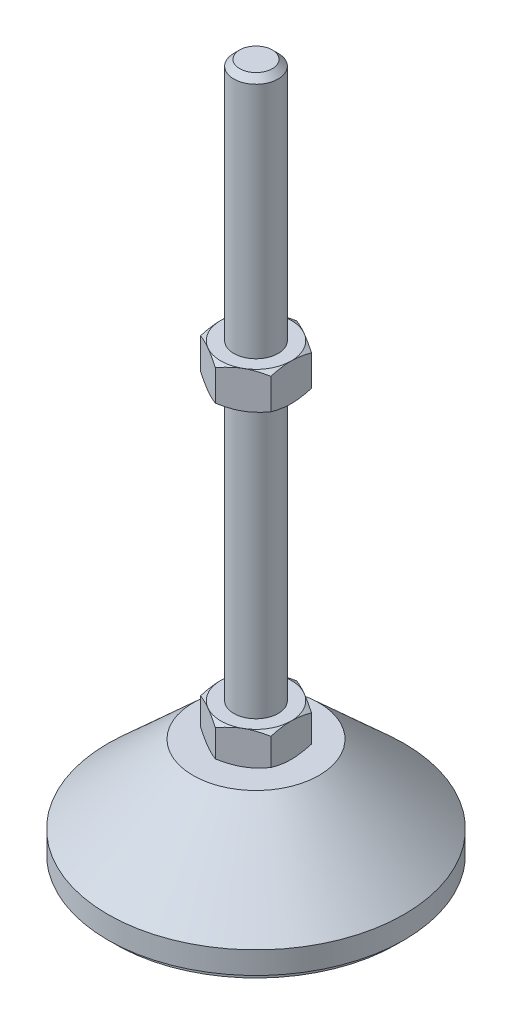
from build123d import *

# Parameters (mm, degrees)
EXTRUDE_1_DEPTH = 9
EXTRUDE_2_DEPTH = 10


with BuildPart() as part:
    # Эскиз1 → Повернуть1 (revolve)
    with BuildSketch(Plane.XY, mode=Mode.PRIVATE) as revolve_1_sk:
        Polygon((0, 0), (-38, 0), (-38, 2), (-40, 2), (-40, 8), (-17, 29), (-6, 29), (-6, 38), (-6, 186.4), (-4.4, 188), (0, 188), align=None)
    revolve(revolve_1_sk.sketch.rotate(Axis((0, 0, 0), (0, 1, 0)), 180), axis=Axis((0, 0, 0), (0, 1, 0)))  # turned: the seam where the file's is

    # Эскиз2 → Бобышка-Вытянуть1 (add)
    with BuildSketch(Plane(origin=(0, 29, 0), x_dir=(1, 0, 0), z_dir=(0, 1, 0))):
        Polygon((0, 10.969655115), (-9.5, 5.484827557), (-9.5, -5.484827557), (0, -10.969655115), (9.5, -5.484827557), (9.5, 5.484827557), align=None)
    extrude(amount=EXTRUDE_1_DEPTH)

    # Эскиз3 → Бобышка-Вытянуть2 (add)
    with BuildSketch(Plane(origin=(0, 112.2, 0), x_dir=(1, 0, 0), z_dir=(0, 1, 0))):
        Polygon((9.5, 5.484827557), (0, 10.969655115), (-9.5, 5.484827557), (-9.5, -5.484827557), (0, -10.969655115), (9.5, -5.484827557), align=None)
    extrude(amount=EXTRUDE_2_DEPTH)

    # Эскиз4 → Вырез-Повернуть2 (revolve, cut)
    with BuildSketch(Plane.XY, mode=Mode.PRIVATE) as cut_revolve_2_sk:
        Polygon((-18.160254038, 122.2), (-9.5, 122.2), (-18.160254038, 117.2), align=None)
        Polygon((-18.160254038, 112.2), (-18.160254038, 117.2), (-9.5, 112.2), align=None)
        Polygon((-17.294228634, 38), (-17.294228634, 33.5), (-9.5, 38), align=None)
        Polygon((-17.294228634, 33.5), (-17.294228634, 29), (-9.5, 29), align=None)
    revolve(cut_revolve_2_sk.sketch.rotate(Axis((0, 188, 0), (0, -1, 0)), 180), axis=Axis((0, 188, 0), (0, -1, 0)), mode=Mode.SUBTRACT)  # turned: the seam where the file's is


solid = part.part
